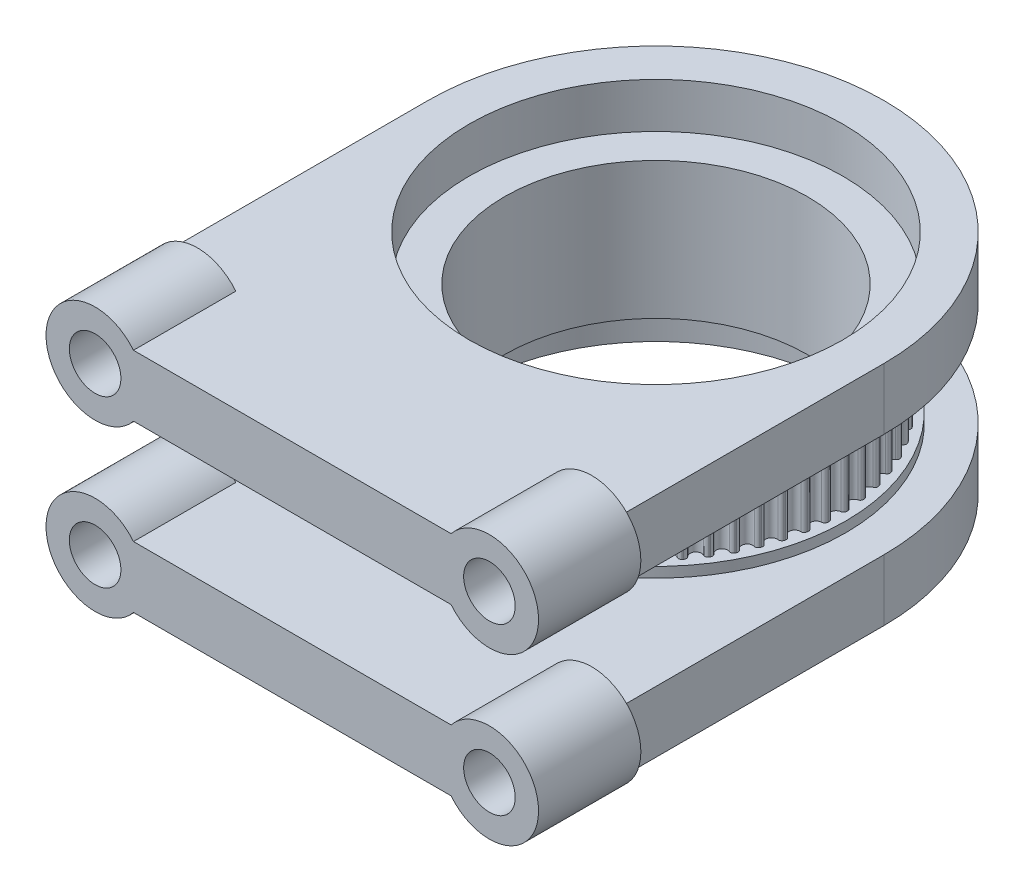
from build123d import *

# Parameters (mm, degrees)
BOSS_EXTRUDE1_DEPTH     = 6.499999954
CIRPATTERN1_COUNT       = 60
SKETCH2_W               = 29.441486473
SKETCH2_H               = 1.5875
BOSS_EXTRUDE3_DEPTH     = 9.525
SKETCH9_R               = 29
CUT_EXTRUDE2_DEPTH      = 7
CUT_EXTRUDE3_DEPTH      = 69.877087402
CUT_EXTRUDE3_DEPTH_BACK = 69.877087402
SKETCH10_R              = 23.5
SKETCH11_R              = 4
CUT_EXTRUDE4_DEPTH      = 12.7
SKETCH11_3_R            = 4
BOSS_EXTRUDE4_DEPTH     = 15.875
MIRROR7_COPY_1_SKETCH_R = 4
MIRROR7_COPY_1_DEPTH    = 12.7
MIRROR7_COPY_2_SKETCH_R = 4
MIRROR7_COPY_2_DEPTH    = 15.875


with BuildPart() as part:
    # Sketch1 → Boss-Extrude1 (new, symmetric)
    with BuildSketch(Plane(origin=(0, 0, 0), x_dir=(1, 0, 0), z_dir=(0, 1, 0))):
        with BuildLine():
            ThreePointArc((0, 27.046736373), (0.58129755, 27.262797831), (0.880356905, 27.806077591))
            ThreePointArc((0.880356905, 27.806077591), (1.057844919, 28.119262803), (1.399698205, 28.232060424))
            ThreePointArc((1.399698205, 28.232060424), (1.479366683, 28.227997893), (1.55902338, 28.223710545))
            ThreePointArc((1.55902338, 28.223710545), (1.887213395, 28.075797443), (2.030992343, 27.745775343))
            ThreePointArc((2.030992343, 27.745775343), (2.271625221, 27.174211512), (2.827153789, 26.898571521))
            ThreePointArc((2.827153789, 26.898571521), (-1.415516811, -27.009669761), (0, 27.046736373))
        make_face()
    boss_extrude1 = extrude(amount=BOSS_EXTRUDE1_DEPTH, both=True)

    # CirPattern1: Boss-Extrude1 ×60 about axis
    cirpattern1_axis = Axis((0, 0, 0), (0, 1, 0))
    for i in range(1, CIRPATTERN1_COUNT):
        add(boss_extrude1.rotate(cirpattern1_axis, i * 360 / CIRPATTERN1_COUNT))

    # Sketch2 → Revolve3 (revolve)
    with BuildSketch(Plane(origin=(0, 0, 0), x_dir=(0, 0, -1), z_dir=(1, 0, 0)), mode=Mode.PRIVATE) as revolve3_sk:
        with Locations((14.720743237, 7.293749954)):
            Rectangle(SKETCH2_W, SKETCH2_H)
    revolve3 = revolve(revolve3_sk.sketch.rotate(Axis((0, 3.3, 0), (0, -1, 0)), 180), axis=Axis((0, 3.3, 0), (0, -1, 0)))

    # Mirror1: Revolve3 across plane
    add(revolve3.mirror(Plane.ZX))

    # Sketch4 → Boss-Extrude3 (add)
    with BuildSketch(Plane(origin=(0, 8.087499954, 0), x_dir=(1, 0, 0), z_dir=(0, 1, 0))):
        with BuildLine():
            Line((-35.35, 0), (-35.35, -56.428986473))
            Line((-35.35, -56.428986473), (35.35, -56.428986473))
            Line((35.35, -56.428986473), (35.35, 0))
            ThreePointArc((35.35, 0), (0, 35.35), (-35.35, 0))
        make_face()
    boss_extrude3 = extrude(amount=BOSS_EXTRUDE3_DEPTH)

    # Sketch9 → Cut-Extrude2 (cut)
    with BuildSketch(Plane(origin=(0, 17.612499954, 0), x_dir=(1, 0, 0), z_dir=(0, 1, 0))):
        with Locations(Location((0, 0, 0), (0, 0, 270))):
            Circle(SKETCH9_R)
    cut_extrude2 = extrude(amount=-CUT_EXTRUDE2_DEPTH, mode=Mode.SUBTRACT)

    # Mirror5: Boss-Extrude3, Cut-Extrude2 across plane
    add(boss_extrude3.mirror(Plane.ZX))
    add(cut_extrude2.mirror(Plane.ZX), mode=Mode.SUBTRACT)

    # Sketch10 → Cut-Extrude3 (cut, two sides: drawn at the far end of the back side and taken through both)
    with BuildSketch(Plane(origin=(0, 0, 0), x_dir=(1, 0, 0), z_dir=(0, 1, 0)).offset(-CUT_EXTRUDE3_DEPTH_BACK)):
        with Locations(Location((0, 0, 0), (0, 0, 270))):
            Circle(SKETCH10_R)
    extrude(amount=CUT_EXTRUDE3_DEPTH + CUT_EXTRUDE3_DEPTH_BACK, mode=Mode.SUBTRACT)

    # Sketch11 → Cut-Extrude4 (cut)
    with BuildSketch(Plane.XY.offset(56.428986473)):
        with Locations((30.5875, -12.849999954)):
            Circle(SKETCH11_R)
    cut_extrude4 = extrude(amount=-CUT_EXTRUDE4_DEPTH, mode=Mode.SUBTRACT)

    # Sketch11_3 → Boss-Extrude4 (add)
    # profile 1 of 2: a face of its own
    with BuildSketch(Plane.XY.offset(56.428986473)):
        with BuildLine():
            ThreePointArc((24.639139407, -17.612499954), (33.111177107, -20.039955021), (38.2075, -12.849999954))
            ThreePointArc((38.2075, -12.849999954), (33.111177107, -5.660044887), (24.639139407, -8.087499954))
            Line((24.639139407, -8.087499954), (35.35, -8.087499954))
            Line((35.35, -8.087499954), (35.35, -17.612499954))
            Line((35.35, -17.612499954), (24.639139407, -17.612499954))
        make_face()
    # profile 2 of 2: a face of its own
    with BuildSketch(Plane.XY.offset(56.428986473)):
        with BuildLine():
            Line((35.35, -8.087499954), (24.639139407, -8.087499954))
            ThreePointArc((24.639139407, -8.087499954), (22.9675, -12.849999954), (24.639139407, -17.612499954))
            Line((24.639139407, -17.612499954), (35.35, -17.612499954))
            Line((35.35, -17.612499954), (35.35, -8.087499954))
        make_face()
        with Locations((30.5875, -12.849999954)):
            Circle(SKETCH11_3_R, mode=Mode.SUBTRACT)
    boss_extrude4 = extrude(amount=-BOSS_EXTRUDE4_DEPTH)

    # Mirror6: Cut-Extrude4, Boss-Extrude4 across plane
    add(cut_extrude4.mirror(Plane.ZX), mode=Mode.SUBTRACT)
    add(boss_extrude4.mirror(Plane.ZX))

    # Mirror7: Cut-Extrude4, Boss-Extrude4 across plane
    add(cut_extrude4.mirror(Plane(origin=(0, 0, 0), x_dir=(0, 0, 1), z_dir=(1, 0, 0))), mode=Mode.SUBTRACT)
    add(boss_extrude4.mirror(Plane(origin=(0, 0, 0), x_dir=(0, 0, 1), z_dir=(1, 0, 0))))

    # Mirror7 copy 1 sketch → Mirror7 copy 1 (cut)
    with BuildSketch(Plane(origin=(0, 0, 56.428986473), x_dir=(-1, 0, 0), z_dir=(0, 0, 1))):
        with Locations((30.5875, -12.849999954)):
            Circle(MIRROR7_COPY_1_SKETCH_R)
    extrude(amount=-MIRROR7_COPY_1_DEPTH, mode=Mode.SUBTRACT)

    # Mirror7 copy 2 sketch → Mirror7 copy 2 (add)
    # profile 1 of 2: a face of its own
    with BuildSketch(Plane(origin=(0, 0, 56.428986473), x_dir=(-1, 0, 0), z_dir=(0, 0, 1))):
        with BuildLine():
            ThreePointArc((24.639139407, -17.612499954), (33.111177107, -20.039955021), (38.2075, -12.849999954))
            ThreePointArc((38.2075, -12.849999954), (33.111177107, -5.660044887), (24.639139407, -8.087499954))
            Line((24.639139407, -8.087499954), (35.35, -8.087499954))
            Line((35.35, -8.087499954), (35.35, -17.612499954))
            Line((35.35, -17.612499954), (24.639139407, -17.612499954))
        make_face()
    # profile 2 of 2: a face of its own
    with BuildSketch(Plane(origin=(0, 0, 56.428986473), x_dir=(-1, 0, 0), z_dir=(0, 0, 1))):
        with BuildLine():
            Line((35.35, -8.087499954), (24.639139407, -8.087499954))
            ThreePointArc((24.639139407, -8.087499954), (22.9675, -12.849999954), (24.639139407, -17.612499954))
            Line((24.639139407, -17.612499954), (35.35, -17.612499954))
            Line((35.35, -17.612499954), (35.35, -8.087499954))
        make_face()
        with Locations((30.5875, -12.849999954)):
            Circle(MIRROR7_COPY_2_SKETCH_R, mode=Mode.SUBTRACT)
    extrude(amount=-MIRROR7_COPY_2_DEPTH)


solid = part.part
